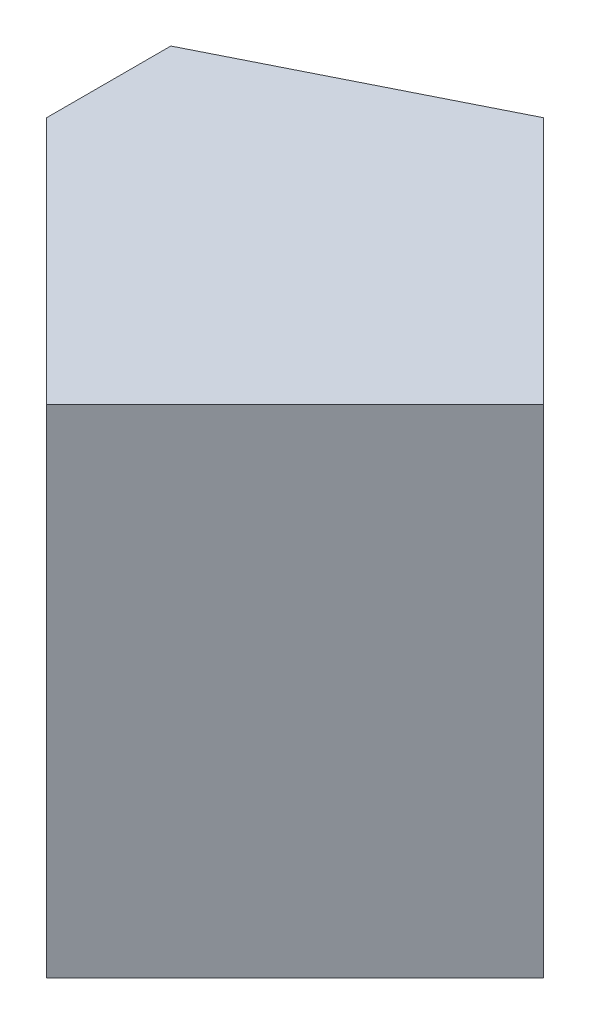
from build123d import *

# Parameters (mm, degrees)
SKETCH1_W           = 20
SKETCH1_H           = 20
BOSS_EXTRUDE1_DEPTH = 20
CUT_EXTRUDE1_DEPTH  = 20
CUT_EXTRUDE2_DEPTH  = 20
CUT_EXTRUDE3_DEPTH  = 20
CUT_EXTRUDE4_DEPTH  = 20


with BuildPart() as part:
    # Sketch1 → Boss-Extrude1 (new body)
    with BuildSketch(Plane.XY):
        with Locations((10, 10)):
            Rectangle(SKETCH1_W, SKETCH1_H)
    extrude(amount=BOSS_EXTRUDE1_DEPTH)

    # Sketch2 → Cut-Extrude1 (cut)
    with BuildSketch(Plane(origin=(0, 20, 0), x_dir=(1, 0, 0), z_dir=(0, 1, 0))):
        Polygon((20, 0), (10, 0), (20, -10), align=None)
    extrude(amount=-CUT_EXTRUDE1_DEPTH, mode=Mode.SUBTRACT)

    # Sketch3 → Cut-Extrude2 (cut)
    with BuildSketch(Plane(origin=(0, 20, 0), x_dir=(1, 0, 0), z_dir=(0, 1, 0))):
        Polygon((20, -20), (10, -20), (20, -10), align=None)
    extrude(amount=-CUT_EXTRUDE2_DEPTH, mode=Mode.SUBTRACT)

    # Sketch4 → Cut-Extrude3 (cut)
    with BuildSketch(Plane(origin=(0, 20, 0), x_dir=(1, 0, 0), z_dir=(0, 1, 0))):
        Polygon((10, -20), (0, -10), (0, -20), align=None)
    extrude(amount=-CUT_EXTRUDE3_DEPTH, mode=Mode.SUBTRACT)

    # Sketch5 → Cut-Extrude4 (cut)
    with BuildSketch(Plane(origin=(0, 20, 0), x_dir=(1, 0, 0), z_dir=(0, 1, 0))):
        Polygon((10, 0), (0, -5), (0, 0), align=None)
    extrude(amount=-CUT_EXTRUDE4_DEPTH, mode=Mode.SUBTRACT)


solid = part.part
